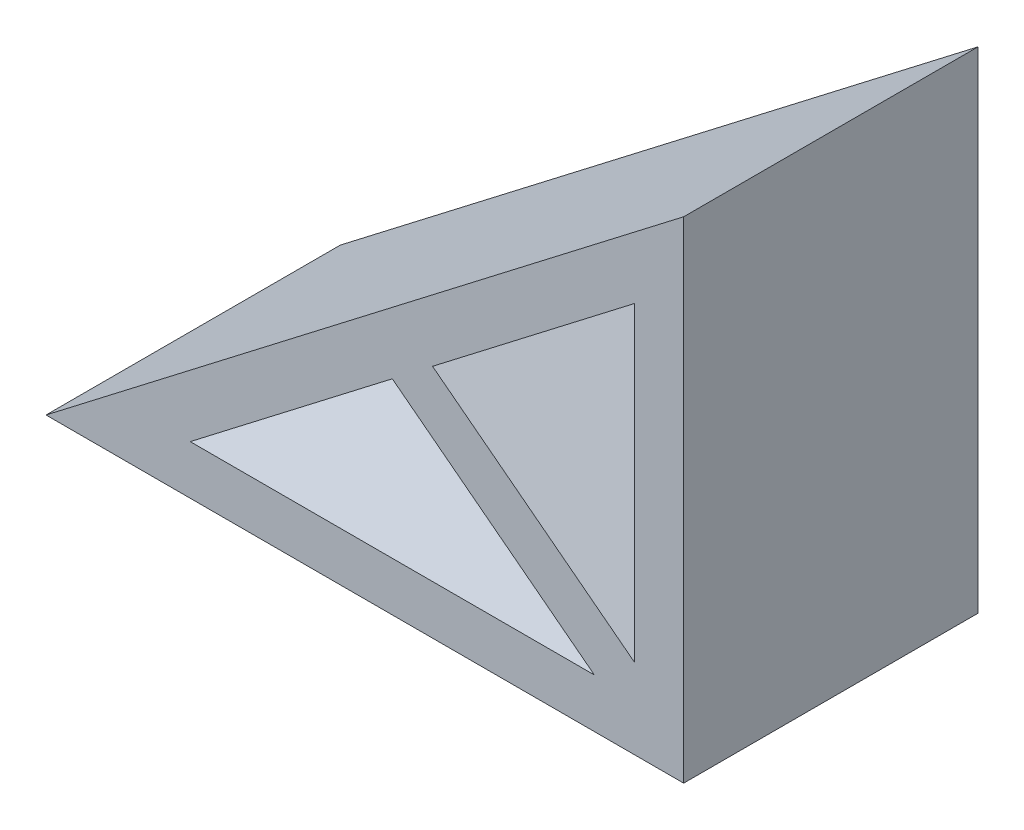
from build123d import *

# Parameters (mm, degrees)
BOSS_EXTRUDE1_DEPTH     = 9.525
CUT_EXTRUDE1_DEPTH      = 10.525
CUT_EXTRUDE1_DEPTH_BACK = 10.525


with BuildPart() as part:
    # Sketch1 → Boss-Extrude1 (new body, symmetric)
    with BuildSketch(Plane.XY):
        Polygon((0, 0), (-41.275, 0), (0, 31.75), align=None)
    extrude(amount=BOSS_EXTRUDE1_DEPTH, both=True)

    # Sketch2 → Cut-Extrude1 (cut, two sides)
    with BuildSketch(Plane.XY) as cut_extrude1_sk:
        Polygon((-3.175, 5.177841223), (-16.255709614, 15.239925542), (-3.175, 25.302009861), align=None)
        Polygon((-5.77869359, 3.175), (-18.859403205, 13.237084319), (-31.940112819, 3.175), align=None)
    extrude(amount=CUT_EXTRUDE1_DEPTH, mode=Mode.SUBTRACT)
    extrude(cut_extrude1_sk.sketch, amount=-CUT_EXTRUDE1_DEPTH_BACK, mode=Mode.SUBTRACT)


solid = part.part
